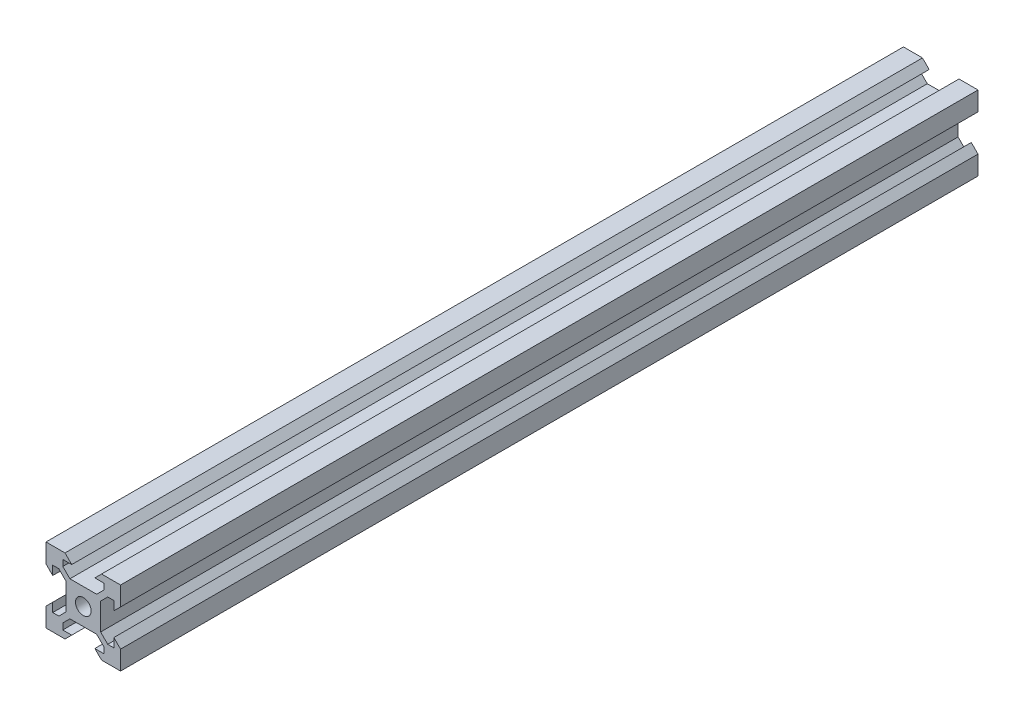
from build123d import *

# Parameters (mm, degrees)
SKETCH1_R           = 2.1
BOSS_EXTRUDE1_DEPTH = 115


with BuildPart() as part:
    # Sketch1 → Boss-Extrude1 (new body, symmetric)
    with BuildSketch(Plane.XY):
        Polygon((5.499339828, 6.56), (3.59, 4.650660172), (-3.59, 4.650660172), (-5.499339828, 6.56), (-5.499339828, 8.2), (-3.1, 8.2), (-4.9, 10), (-10, 10), (-10, 4.9), (-8.2, 3.1), (-8.2, 5.499339828), (-6.56, 5.499339828), (-4.650660172, 3.59), (-4.650660172, -3.59), (-6.56, -5.499339828), (-8.2, -5.499339828), (-8.2, -3.1), (-10, -4.9), (-10, -10), (-4.9, -10), (-3.1, -8.2), (-5.499339828, -8.2), (-5.499339828, -6.56), (-3.59, -4.650660172), (3.59, -4.650660172), (5.499339828, -6.56), (5.499339828, -8.2), (3.1, -8.2), (4.9, -10), (10, -10), (10, -4.9), (8.2, -3.1), (8.2, -5.499339828), (6.56, -5.499339828), (4.650660172, -3.59), (4.650660172, 3.59), (6.56, 5.499339828), (8.2, 5.499339828), (8.2, 3.1), (10, 4.9), (10, 10), (4.9, 10), (3.1, 8.2), (5.499339828, 8.2), align=None)
        Circle(SKETCH1_R, mode=Mode.SUBTRACT)
    extrude(amount=BOSS_EXTRUDE1_DEPTH, both=True)


solid = part.part
